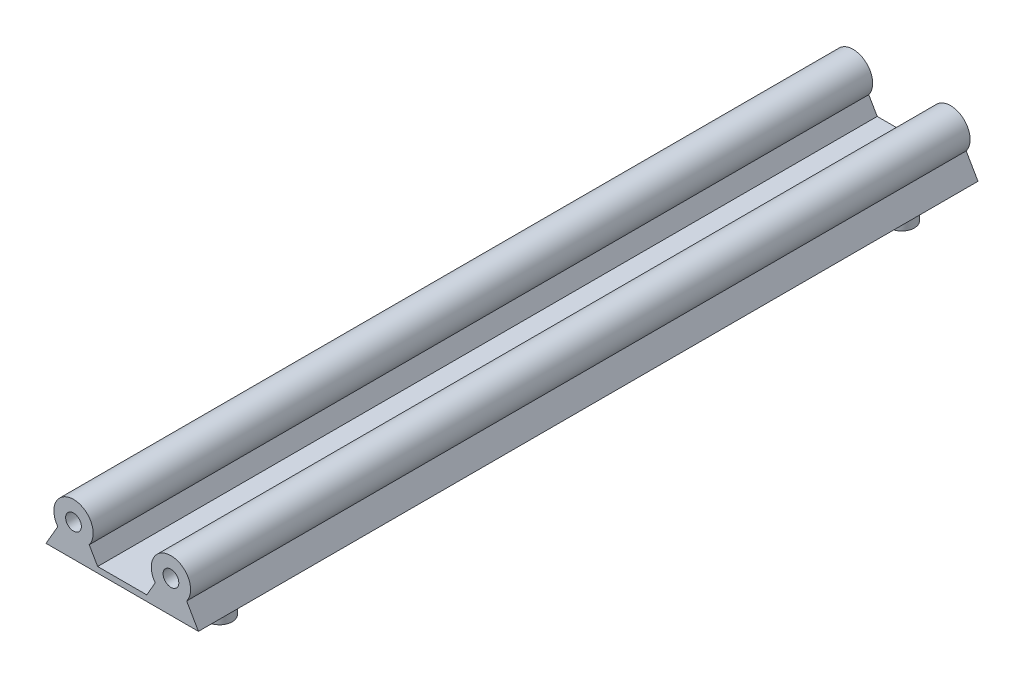
from build123d import *

# Parameters (mm, degrees)
SKETCH1_R           = 5
BOSS_EXTRUDE1_DEPTH = 220
SKETCH4_R           = 3.2
BOSS_EXTRUDE3_DEPTH = 6
BOSS_EXTRUDE4_DEPTH = 220
SKETCH5_R           = 1.37
CUT_EXTRUDE1_DEPTH  = 7
SKETCH6_R           = 1.37
CUT_EXTRUDE2_DEPTH  = 7
SKETCH7_R           = 3.2
CUT_EXTRUDE3_DEPTH  = 6
CUT_EXTRUDE4_DEPTH  = 10.8
CUT_EXTRUDE5_DEPTH  = 10.8
SKETCH11_R          = 2
CUT_EXTRUDE6_DEPTH  = 7
SKETCH12_R          = 2
CUT_EXTRUDE7_DEPTH  = 7


with BuildPart() as part:
    # Sketch1 → Boss-Extrude1 (new body)
    with BuildSketch(Plane.XY):
        Circle(SKETCH1_R)
        with BuildLine():
            Line((-4, -3), (-7, -8.196152423))
            Line((-7, -8.196152423), (7, -8.196152423))
            Line((7, -8.196152423), (4, -3))
            ThreePointArc((4, -3), (0, 5), (-4, -3))
        make_face()
        with BuildLine():
            Line((28.8, -3), (31.8, -8.196152423))
            Line((31.8, -8.196152423), (17.8, -8.196152423))
            Line((17.8, -8.196152423), (20.8, -3))
            ThreePointArc((20.8, -3), (24.8, 5), (28.8, -3))
        make_face()
    extrude(amount=BOSS_EXTRUDE1_DEPTH)

    # Sketch4 → Boss-Extrude3 (add)
    with BuildSketch(Plane.XZ.offset(8.196152423)):
        with Locations((0, 196.8)):
            Circle(SKETCH4_R)
        with Locations((24.8, 196.8)):
            Circle(SKETCH4_R)
        with Locations((24.8, 172)):
            Circle(SKETCH4_R)
        with Locations((24.8, 147.2)):
            Circle(SKETCH4_R)
        with Locations((24.8, 122.4)):
            Circle(SKETCH4_R)
        with Locations((24.8, 97.6)):
            Circle(SKETCH4_R)
        with Locations((24.8, 72.8)):
            Circle(SKETCH4_R)
        with Locations((24.8, 48)):
            Circle(SKETCH4_R)
        with Locations((24.8, 23.2)):
            Circle(SKETCH4_R)
        with Locations((0, 172)):
            Circle(SKETCH4_R)
        with Locations((0, 147.2)):
            Circle(SKETCH4_R)
        with Locations((0, 122.4)):
            Circle(SKETCH4_R)
        with Locations((0, 97.6)):
            Circle(SKETCH4_R)
        with Locations((0, 72.8)):
            Circle(SKETCH4_R)
        with Locations((0, 48)):
            Circle(SKETCH4_R)
        with Locations((0, 23.2)):
            Circle(SKETCH4_R)
    extrude(amount=BOSS_EXTRUDE3_DEPTH)

    # Sketch3 → Boss-Extrude4 (add)
    with BuildSketch(Plane.XY.offset(220)):
        Polygon((7, -8.196152423), (17.8, -8.196152423), (18.65, -8.196152423), (18.65, -6.723909236), (6.15, -6.723909236), (6.15, -8.196152423), align=None)
    extrude(amount=-BOSS_EXTRUDE4_DEPTH)

    # Sketch5 → Cut-Extrude1 (cut)
    with BuildSketch(Plane(origin=(0, 0, 0), x_dir=(-1, 0, 0), z_dir=(0, 0, -1))):
        Circle(SKETCH5_R)
        with Locations((-24.8, 0)):
            Circle(SKETCH5_R)
    extrude(amount=-CUT_EXTRUDE1_DEPTH, mode=Mode.SUBTRACT)

    # Sketch6 → Cut-Extrude2 (cut)
    with BuildSketch(Plane.XY.offset(220)):
        Circle(SKETCH6_R)
        with Locations((24.8, 0)):
            Circle(SKETCH6_R)
    extrude(amount=-CUT_EXTRUDE2_DEPTH, mode=Mode.SUBTRACT)

    # Sketch7 → Cut-Extrude3 (cut)
    with BuildSketch(Plane.XZ.offset(14.196152423)):
        with Locations((0, 172)):
            Circle(SKETCH7_R)
        with Locations((24.8, 172)):
            Circle(SKETCH7_R)
        with Locations((24.8, 147.2)):
            Circle(SKETCH7_R)
        with Locations((24.8, 122.4)):
            Circle(SKETCH7_R)
        with Locations((24.8, 97.6)):
            Circle(SKETCH7_R)
        with Locations((24.8, 72.8)):
            Circle(SKETCH7_R)
        with Locations((24.8, 48)):
            Circle(SKETCH7_R)
        with Locations((0, 147.2)):
            Circle(SKETCH7_R)
        with Locations((0, 122.4)):
            Circle(SKETCH7_R)
        with Locations((0, 97.6)):
            Circle(SKETCH7_R)
        with Locations((0, 72.8)):
            Circle(SKETCH7_R)
        with Locations((0, 48)):
            Circle(SKETCH7_R)
    extrude(amount=-CUT_EXTRUDE3_DEPTH, mode=Mode.SUBTRACT)

    # Sketch9 → Cut-Extrude4 (cut)
    with BuildSketch(Plane(origin=(0, 0, 0), x_dir=(-1, 0, 0), z_dir=(0, 0, -1))):
        with BuildLine():
            Line((-28.8, -3), (-31.8, -8.196152423))
            Line((-31.8, -8.196152423), (7, -8.196152423))
            Line((7, -8.196152423), (4, -3))
            ThreePointArc((4, -3), (0, 5), (-4, -3))
            Line((-4, -3), (-6.15, -6.723909236))
            Line((-6.15, -6.723909236), (-18.65, -6.723909236))
            Line((-18.65, -6.723909236), (-20.8, -3))
            ThreePointArc((-20.8, -3), (-24.8, 5), (-28.8, -3))
        make_face()
    extrude(amount=-CUT_EXTRUDE4_DEPTH, mode=Mode.SUBTRACT)

    # Sketch10 → Cut-Extrude5 (cut)
    with BuildSketch(Plane.XY.offset(220)):
        with BuildLine():
            Line((20.8, -3), (18.65, -6.723909236))
            Line((18.65, -6.723909236), (6.15, -6.723909236))
            Line((6.15, -6.723909236), (4, -3))
            ThreePointArc((4, -3), (0, 5), (-4, -3))
            Line((-4, -3), (-7, -8.196152423))
            Line((-7, -8.196152423), (31.8, -8.196152423))
            Line((31.8, -8.196152423), (28.8, -3))
            ThreePointArc((28.8, -3), (24.8, 5), (20.8, -3))
        make_face()
    extrude(amount=-CUT_EXTRUDE5_DEPTH, mode=Mode.SUBTRACT)

    # Sketch11 → Cut-Extrude6 (cut)
    with BuildSketch(Plane.XY.offset(209.2)):
        Circle(SKETCH11_R)
        with Locations((24.8, 0)):
            Circle(SKETCH11_R)
    extrude(amount=-CUT_EXTRUDE6_DEPTH, mode=Mode.SUBTRACT)

    # Sketch12 → Cut-Extrude7 (cut)
    with BuildSketch(Plane(origin=(0, 0, 10.8), x_dir=(-1, 0, 0), z_dir=(0, 0, -1))):
        Circle(SKETCH12_R)
        with Locations((-24.8, 0)):
            Circle(SKETCH12_R)
    extrude(amount=-CUT_EXTRUDE7_DEPTH, mode=Mode.SUBTRACT)


solid = part.part
